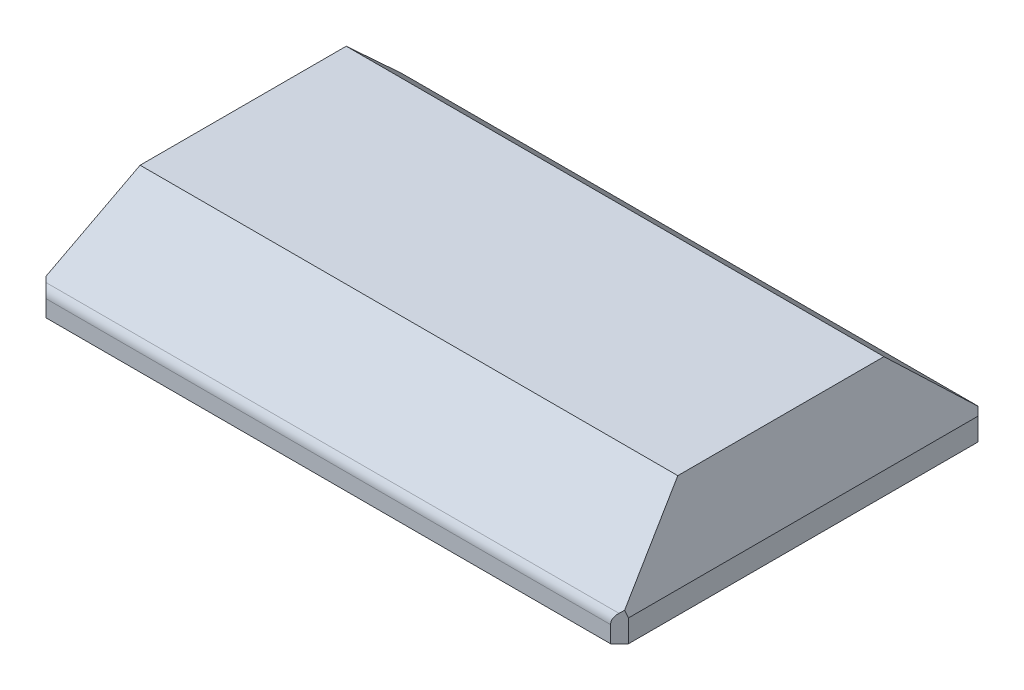
from build123d import *

# Parameters (mm, degrees)
SKETCH1_W           = 130
SKETCH1_H           = 82
BOSS_EXTRUDE1_DEPTH = 5
SKETCH3_W           = 130
SKETCH3_H           = 82
SKETCH2_W           = 120
SKETCH2_H           = 46
CHAMFER1_SIZE       = 2
SKETCH4_R           = 1.2
CUT_EXTRUDE1_DEPTH  = 6
SKETCH5_W           = 114
SKETCH5_H           = 40
CUT_EXTRUDE2_DEPTH  = 21
SKETCH6_W           = 118
SKETCH6_H           = 56
CUT_EXTRUDE3_DEPTH  = 12
SKETCH8_W           = 7
SKETCH8_H           = 7
BOSS_EXTRUDE2_DEPTH = 8
SKETCH9_R           = 2.1
CUT_EXTRUDE4_DEPTH  = 8
SKETCH10_W          = 2
SKETCH10_H          = 40
CUT_EXTRUDE5_DEPTH  = 9
FILLET1_R           = 3


with BuildPart() as part:
    # Sketch1 → Boss-Extrude1 (new body)
    with BuildSketch(Plane(origin=(0, 0, 0), x_dir=(1, 0, 0), z_dir=(0, 1, 0))):
        Rectangle(SKETCH1_W, SKETCH1_H)
    extrude(amount=BOSS_EXTRUDE1_DEPTH)

    # Sketch3 → Loft2 section 0
    with BuildSketch(Plane(origin=(0, 5, 0), x_dir=(1, 0, 0), z_dir=(0, 1, 0))):
        Rectangle(SKETCH3_W, SKETCH3_H)
    # Sketch2 → Loft2 section 1
    with BuildSketch(Plane(origin=(0, 22, 0), x_dir=(1, 0, 0), z_dir=(0, 1, 0))):
        Rectangle(SKETCH2_W, SKETCH2_H)
    loft()

    # Chamfer1
    chamfer1_edges = [part.edges().sort_by_distance(p)[0] for p in [
        (-65, 2.5, 41),
        (65, 2.5, 41),
        (65, 2.5, -41),
        (-65, 2.5, -41),
    ]]
    chamfer(chamfer1_edges, length=CHAMFER1_SIZE)

    # Sketch4 → Cut-Extrude1 (cut)
    with BuildSketch(Plane.XZ):
        with Locations((40, -37.5)):
            Circle(SKETCH4_R)
        with Locations((-40, -37.5)):
            Circle(SKETCH4_R)
    cut_extrude1 = extrude(amount=-CUT_EXTRUDE1_DEPTH, mode=Mode.SUBTRACT)

    # Sketch5 → Cut-Extrude2 (cut)
    with BuildSketch(Plane.XZ):
        Rectangle(SKETCH5_W, SKETCH5_H)
    extrude(amount=-CUT_EXTRUDE2_DEPTH, mode=Mode.SUBTRACT)

    # Mirror1: Cut-Extrude1 across plane
    add(cut_extrude1.mirror(Plane.XY), mode=Mode.SUBTRACT)

    # Sketch6 → Cut-Extrude3 (cut)
    with BuildSketch(Plane.XZ):
        Rectangle(SKETCH6_W, SKETCH6_H)
    extrude(amount=-CUT_EXTRUDE3_DEPTH, mode=Mode.SUBTRACT)

    # Sketch8 → Boss-Extrude2 (add)
    with BuildSketch(Plane(origin=(0, 4, 0), x_dir=(-1, 0, 0), z_dir=(0, -1, 0))):
        with Locations((-55.5, 24.5)):
            Rectangle(SKETCH8_W, SKETCH8_H)
        with Locations((-55.5, -24.5)):
            Rectangle(SKETCH8_W, SKETCH8_H)
        with Locations((55.5, -24.5)):
            Rectangle(SKETCH8_W, SKETCH8_H)
        with Locations((55.5, 24.5)):
            Rectangle(SKETCH8_W, SKETCH8_H)
    extrude(amount=-BOSS_EXTRUDE2_DEPTH)

    # Sketch9 → Cut-Extrude4 (cut)
    with BuildSketch(Plane.XZ.offset(-4)):
        with Locations((-55.5, 24.5)):
            Circle(SKETCH9_R)
        with Locations((55.5, 24.5)):
            Circle(SKETCH9_R)
        with Locations((55.5, -24.5)):
            Circle(SKETCH9_R)
        with Locations((-55.5, -24.5)):
            Circle(SKETCH9_R)
    extrude(amount=-CUT_EXTRUDE4_DEPTH, mode=Mode.SUBTRACT)

    # Sketch10 → Cut-Extrude5 (cut)
    with BuildSketch(Plane.XZ.offset(-12)):
        with Locations((-58, 0)):
            Rectangle(SKETCH10_W, SKETCH10_H)
        with Locations((58, 0)):
            Rectangle(SKETCH10_W, SKETCH10_H)
    extrude(amount=-CUT_EXTRUDE5_DEPTH, mode=Mode.SUBTRACT)

    # Fillet1
    fillet1_edges = [part.edges().sort_by_distance(p)[0] for p in [
        (0, 5, 41),
        (0, 5, -41),
    ]]
    fillet(fillet1_edges, radius=FILLET1_R)


solid = part.part
